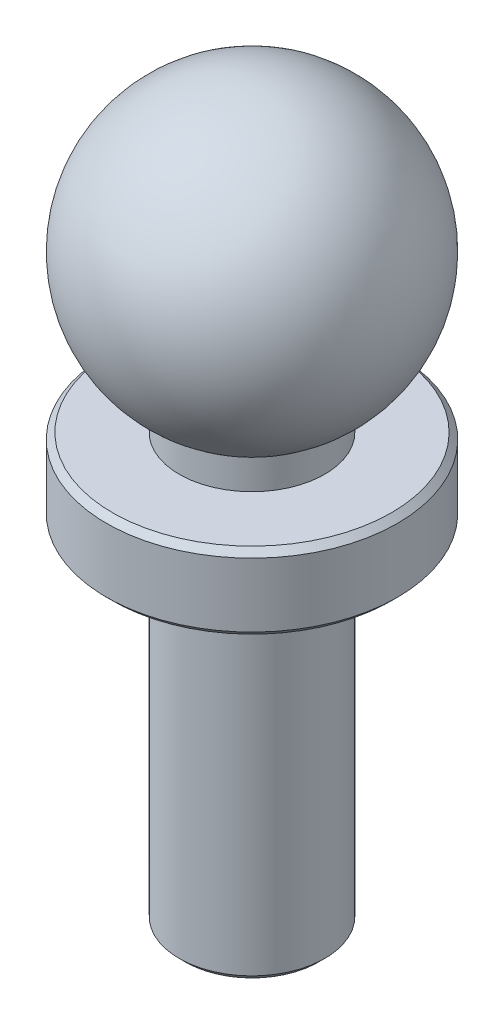
from build123d import *

# Parameters (mm, degrees)
CHAMFER1_SIZE = 0.2


with BuildPart() as part:
    # Sketch1 → Revolve1 (revolve)
    with BuildSketch(Plane.XY, mode=Mode.PRIVATE) as revolve1_sk:
        with BuildLine():
            Line((2.38125, 3.495554014), (2.38125, 2.495554014))
            Line((2.38125, 2.495554014), (4.7625, 2.495554014))
            Line((4.7625, 2.495554014), (4.7625, 0))
            Line((4.7625, 0), (2.38125, 0))
            Line((2.38125, 0), (2.38125, -11.43))
            Line((2.38125, -11.43), (0, -11.43))
            Line((0, -11.43), (0, 12.3825))
            ThreePointArc((0, 12.3825), (4.600221748, 8.852625702), (2.38125, 3.495554014))
        make_face()
    revolve(revolve1_sk.sketch.rotate(Axis((0, 48.717648678, 0), (0, -1, 0)), 180), axis=Axis((0, 48.717648678, 0), (0, -1, 0)))  # turned: the seam where the file's is

    # Chamfer1
    chamfer1_edges = [part.edges().sort_by_distance(p)[0] for p in [
        (2.38125, -11.43, 0),
        (4.7625, 0, 0),
        (4.7625, 2.495554014, 0),
    ]]
    chamfer(chamfer1_edges, length=CHAMFER1_SIZE)


solid = part.part
